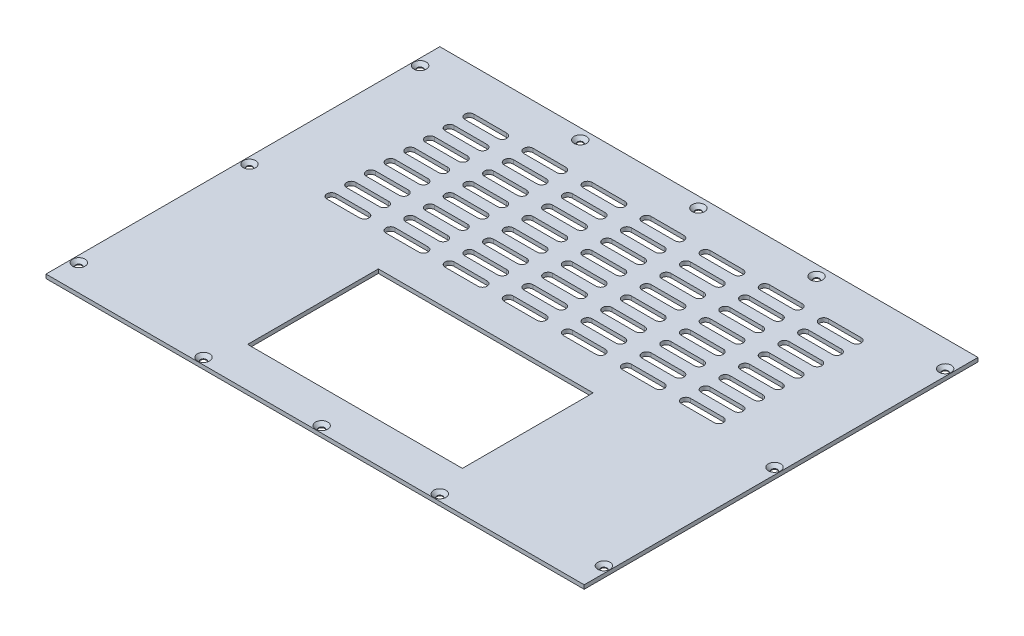
from build123d import *

# Parameters (mm, degrees)
SKETCH_1_W                   = 410
SKETCH_1_H                   = 300
EXTRUDE_1_DEPTH              = 3
HOLE_WIZARD_M4_1_AT_2_COUNT  = 2
HOLE_WIZARD_M4_1_AT_2_PITCH  = 90
HOLE_WIZARD_M4_1_AT_3_COUNT  = 2
HOLE_WIZARD_M4_1_AT_3_PITCH  = 90
HOLE_WIZARD_M4_1_AT_4_COUNT  = 2
HOLE_WIZARD_M4_1_AT_4_PITCH  = 245.283509433
HOLE_WIZARD_M4_1_AT_5_COUNT  = 2
HOLE_WIZARD_M4_1_AT_5_PITCH  = 287
HOLE_WIZARD_M4_1_AT_6_COUNT  = 2
HOLE_WIZARD_M4_1_AT_6_PITCH  = 245.283509433
HOLE_WIZARD_M4_1_AT_7_COUNT  = 2
HOLE_WIZARD_M4_1_AT_7_PITCH  = 200.359676582
HOLE_WIZARD_M4_1_AT_8_COUNT  = 2
HOLE_WIZARD_M4_1_AT_8_PITCH  = 337.615165536
HOLE_WIZARD_M4_1_AT_9_COUNT  = 2
HOLE_WIZARD_M4_1_AT_9_PITCH  = 337.615165536
HOLE_WIZARD_M4_1_AT_10_COUNT = 2
HOLE_WIZARD_M4_1_AT_10_PITCH = 200.359676582
HOLE_WIZARD_M4_1_AT_11_COUNT = 2
HOLE_WIZARD_M4_1_AT_11_PITCH = 300.780650973
HOLE_WIZARD_M4_1_AT_12_COUNT = 2
HOLE_WIZARD_M4_1_AT_12_PITCH = 300.780650973
SKETCH_12_W                  = 163.6
SKETCH_12_H                  = 99.6
CUT_EXTRUDE_1_DEPTH          = 4
CUT_EXTRUDE_3_DEPTH          = 10


with BuildPart() as part:
    # 草圖1 → 填料-伸長1 (new body)
    with BuildSketch(Plane(origin=(0, 0, 0), x_dir=(1, 0, 0), z_dir=(0, 1, 0))):
        Rectangle(SKETCH_1_W, SKETCH_1_H)
    extrude(amount=EXTRUDE_1_DEPTH)

    # 草圖3 → M4 錐坑平頭螺釘的錐孔1 (revolve, cut)
    with BuildSketch(Plane(origin=(0, 3, -142), x_dir=(0, 0, 1), z_dir=(1, 0, 0))):
        Polygon((0, 0), (0, 3), (2.25, 3), (2.25, 2.45), (4.7, 0), align=None)
    hole_wizard_m4_1 = revolve(axis=Axis((0, 9.35, -142), (0, -1, 0)), mode=Mode.SUBTRACT)

    # M4 錐坑平頭螺釘的錐孔1 at 2: M4 錐坑平頭螺釘的錐孔1 ×2
    with Locations(*[(-i * HOLE_WIZARD_M4_1_AT_2_PITCH, 0, 0) for i in range(1, HOLE_WIZARD_M4_1_AT_2_COUNT)]):
        add(hole_wizard_m4_1, mode=Mode.SUBTRACT)

    # M4 錐坑平頭螺釘的錐孔1 at 3: M4 錐坑平頭螺釘的錐孔1 ×2
    with Locations(*[(i * HOLE_WIZARD_M4_1_AT_3_PITCH, 0, 0) for i in range(1, HOLE_WIZARD_M4_1_AT_3_COUNT)]):
        add(hole_wizard_m4_1, mode=Mode.SUBTRACT)

    # M4 錐坑平頭螺釘的錐孔1 at 4: M4 錐坑平頭螺釘的錐孔1 ×2
    with Locations(*[Vector(0.815382985, 0, 0.578921919) * (i * HOLE_WIZARD_M4_1_AT_4_PITCH) for i in range(1, HOLE_WIZARD_M4_1_AT_4_COUNT)]):
        add(hole_wizard_m4_1, mode=Mode.SUBTRACT)

    # M4 錐坑平頭螺釘的錐孔1 at 5: M4 錐坑平頭螺釘的錐孔1 ×2
    with Locations(*[(0, 0, i * HOLE_WIZARD_M4_1_AT_5_PITCH) for i in range(1, HOLE_WIZARD_M4_1_AT_5_COUNT)]):
        add(hole_wizard_m4_1, mode=Mode.SUBTRACT)

    # M4 錐坑平頭螺釘的錐孔1 at 6: M4 錐坑平頭螺釘的錐孔1 ×2
    with Locations(*[Vector(-0.815382985, 0, 0.578921919) * (i * HOLE_WIZARD_M4_1_AT_6_PITCH) for i in range(1, HOLE_WIZARD_M4_1_AT_6_COUNT)]):
        add(hole_wizard_m4_1, mode=Mode.SUBTRACT)

    # M4 錐坑平頭螺釘的錐孔1 at 7: M4 錐坑平頭螺釘的錐孔1 ×2
    with Locations(*[Vector(0.998204845, 0, 0.059892291) * (i * HOLE_WIZARD_M4_1_AT_7_PITCH) for i in range(1, HOLE_WIZARD_M4_1_AT_7_COUNT)]):
        add(hole_wizard_m4_1, mode=Mode.SUBTRACT)

    # M4 錐坑平頭螺釘的錐孔1 at 8: M4 錐坑平頭螺釘的錐孔1 ×2
    with Locations(*[Vector(0.59239045, 0, 0.805651013) * (i * HOLE_WIZARD_M4_1_AT_8_PITCH) for i in range(1, HOLE_WIZARD_M4_1_AT_8_COUNT)]):
        add(hole_wizard_m4_1, mode=Mode.SUBTRACT)

    # M4 錐坑平頭螺釘的錐孔1 at 9: M4 錐坑平頭螺釘的錐孔1 ×2
    with Locations(*[Vector(-0.59239045, 0, 0.805651013) * (i * HOLE_WIZARD_M4_1_AT_9_PITCH) for i in range(1, HOLE_WIZARD_M4_1_AT_9_COUNT)]):
        add(hole_wizard_m4_1, mode=Mode.SUBTRACT)

    # M4 錐坑平頭螺釘的錐孔1 at 10: M4 錐坑平頭螺釘的錐孔1 ×2
    with Locations(*[Vector(-0.998204845, 0, 0.059892291) * (i * HOLE_WIZARD_M4_1_AT_10_PITCH) for i in range(1, HOLE_WIZARD_M4_1_AT_10_COUNT)]):
        add(hole_wizard_m4_1, mode=Mode.SUBTRACT)

    # M4 錐坑平頭螺釘的錐孔1 at 11: M4 錐坑平頭螺釘的錐孔1 ×2
    with Locations(*[Vector(0.299221375, 0, 0.954183719) * (i * HOLE_WIZARD_M4_1_AT_11_PITCH) for i in range(1, HOLE_WIZARD_M4_1_AT_11_COUNT)]):
        add(hole_wizard_m4_1, mode=Mode.SUBTRACT)

    # M4 錐坑平頭螺釘的錐孔1 at 12: M4 錐坑平頭螺釘的錐孔1 ×2
    with Locations(*[Vector(-0.299221375, 0, 0.954183719) * (i * HOLE_WIZARD_M4_1_AT_12_PITCH) for i in range(1, HOLE_WIZARD_M4_1_AT_12_COUNT)]):
        add(hole_wizard_m4_1, mode=Mode.SUBTRACT)

    # 草圖12 → 除料-伸長1 (cut, through all)
    with BuildSketch(Plane.XZ):
        with Locations((0, 69.8)):
            Rectangle(SKETCH_12_W, SKETCH_12_H)
    extrude(amount=-CUT_EXTRUDE_1_DEPTH, mode=Mode.SUBTRACT)

    # 草圖13 → 除料-伸長3 (cut)
    with BuildSketch(Plane(origin=(0, 3, 0), x_dir=(1, 0, 0), z_dir=(0, 1, 0))):
        with BuildLine():
            Line((-147.5, 118.5), (-122.5, 118.5))
            ThreePointArc((-122.5, 118.5), (-119, 115), (-122.5, 111.5))
            Line((-122.5, 111.5), (-147.5, 111.5))
            ThreePointArc((-147.5, 111.5), (-151, 115), (-147.5, 118.5))
        make_face()
        with BuildLine():
            Line((-102.5, 118.5), (-77.5, 118.5))
            ThreePointArc((-77.5, 118.5), (-74, 115), (-77.5, 111.5))
            Line((-77.5, 111.5), (-102.5, 111.5))
            ThreePointArc((-102.5, 111.5), (-106, 115), (-102.5, 118.5))
        make_face()
        with BuildLine():
            Line((-57.5, 118.5), (-32.5, 118.5))
            ThreePointArc((-32.5, 118.5), (-29, 115), (-32.5, 111.5))
            Line((-32.5, 111.5), (-57.5, 111.5))
            ThreePointArc((-57.5, 111.5), (-61, 115), (-57.5, 118.5))
        make_face()
        with BuildLine():
            Line((-12.5, 118.5), (12.5, 118.5))
            ThreePointArc((12.5, 118.5), (16, 115), (12.5, 111.5))
            Line((12.5, 111.5), (-12.5, 111.5))
            ThreePointArc((-12.5, 111.5), (-16, 115), (-12.5, 118.5))
        make_face()
        with BuildLine():
            Line((32.5, 118.5), (57.5, 118.5))
            ThreePointArc((57.5, 118.5), (61, 115), (57.5, 111.5))
            Line((57.5, 111.5), (32.5, 111.5))
            ThreePointArc((32.5, 111.5), (29, 115), (32.5, 118.5))
        make_face()
        with BuildLine():
            Line((77.5, 118.5), (102.5, 118.5))
            ThreePointArc((102.5, 118.5), (106, 115), (102.5, 111.5))
            Line((102.5, 111.5), (77.5, 111.5))
            ThreePointArc((77.5, 111.5), (74, 115), (77.5, 118.5))
        make_face()
        with BuildLine():
            Line((122.5, 118.5), (147.5, 118.5))
            ThreePointArc((147.5, 118.5), (151, 115), (147.5, 111.5))
            Line((147.5, 111.5), (122.5, 111.5))
            ThreePointArc((122.5, 111.5), (119, 115), (122.5, 118.5))
        make_face()
        with BuildLine():
            Line((-102.5, 103.5), (-77.5, 103.5))
            ThreePointArc((-77.5, 103.5), (-74, 100), (-77.5, 96.5))
            Line((-77.5, 96.5), (-102.5, 96.5))
            ThreePointArc((-102.5, 96.5), (-106, 100), (-102.5, 103.5))
        make_face()
        with BuildLine():
            Line((-57.5, 103.5), (-32.5, 103.5))
            ThreePointArc((-32.5, 103.5), (-29, 100), (-32.5, 96.5))
            Line((-32.5, 96.5), (-57.5, 96.5))
            ThreePointArc((-57.5, 96.5), (-61, 100), (-57.5, 103.5))
        make_face()
        with BuildLine():
            Line((-12.5, 103.5), (12.5, 103.5))
            ThreePointArc((12.5, 103.5), (16, 100), (12.5, 96.5))
            Line((12.5, 96.5), (-12.5, 96.5))
            ThreePointArc((-12.5, 96.5), (-16, 100), (-12.5, 103.5))
        make_face()
        with BuildLine():
            Line((32.5, 103.5), (57.5, 103.5))
            ThreePointArc((57.5, 103.5), (61, 100), (57.5, 96.5))
            Line((57.5, 96.5), (32.5, 96.5))
            ThreePointArc((32.5, 96.5), (29, 100), (32.5, 103.5))
        make_face()
        with BuildLine():
            Line((77.5, 103.5), (102.5, 103.5))
            ThreePointArc((102.5, 103.5), (106, 100), (102.5, 96.5))
            Line((102.5, 96.5), (77.5, 96.5))
            ThreePointArc((77.5, 96.5), (74, 100), (77.5, 103.5))
        make_face()
        with BuildLine():
            Line((122.5, 103.5), (147.5, 103.5))
            ThreePointArc((147.5, 103.5), (151, 100), (147.5, 96.5))
            Line((147.5, 96.5), (122.5, 96.5))
            ThreePointArc((122.5, 96.5), (119, 100), (122.5, 103.5))
        make_face()
        with BuildLine():
            Line((-102.5, 88.5), (-77.5, 88.5))
            ThreePointArc((-77.5, 88.5), (-74, 85), (-77.5, 81.5))
            Line((-77.5, 81.5), (-102.5, 81.5))
            ThreePointArc((-102.5, 81.5), (-106, 85), (-102.5, 88.5))
        make_face()
        with BuildLine():
            Line((-57.5, 88.5), (-32.5, 88.5))
            ThreePointArc((-32.5, 88.5), (-29, 85), (-32.5, 81.5))
            Line((-32.5, 81.5), (-57.5, 81.5))
            ThreePointArc((-57.5, 81.5), (-61, 85), (-57.5, 88.5))
        make_face()
        with BuildLine():
            Line((-12.5, 88.5), (12.5, 88.5))
            ThreePointArc((12.5, 88.5), (16, 85), (12.5, 81.5))
            Line((12.5, 81.5), (-12.5, 81.5))
            ThreePointArc((-12.5, 81.5), (-16, 85), (-12.5, 88.5))
        make_face()
        with BuildLine():
            Line((32.5, 88.5), (57.5, 88.5))
            ThreePointArc((57.5, 88.5), (61, 85), (57.5, 81.5))
            Line((57.5, 81.5), (32.5, 81.5))
            ThreePointArc((32.5, 81.5), (29, 85), (32.5, 88.5))
        make_face()
        with BuildLine():
            Line((77.5, 88.5), (102.5, 88.5))
            ThreePointArc((102.5, 88.5), (106, 85), (102.5, 81.5))
            Line((102.5, 81.5), (77.5, 81.5))
            ThreePointArc((77.5, 81.5), (74, 85), (77.5, 88.5))
        make_face()
        with BuildLine():
            Line((122.5, 88.5), (147.5, 88.5))
            ThreePointArc((147.5, 88.5), (151, 85), (147.5, 81.5))
            Line((147.5, 81.5), (122.5, 81.5))
            ThreePointArc((122.5, 81.5), (119, 85), (122.5, 88.5))
        make_face()
        with BuildLine():
            Line((-102.5, 73.5), (-77.5, 73.5))
            ThreePointArc((-77.5, 73.5), (-74, 70), (-77.5, 66.5))
            Line((-77.5, 66.5), (-102.5, 66.5))
            ThreePointArc((-102.5, 66.5), (-106, 70), (-102.5, 73.5))
        make_face()
        with BuildLine():
            Line((-57.5, 73.5), (-32.5, 73.5))
            ThreePointArc((-32.5, 73.5), (-29, 70), (-32.5, 66.5))
            Line((-32.5, 66.5), (-57.5, 66.5))
            ThreePointArc((-57.5, 66.5), (-61, 70), (-57.5, 73.5))
        make_face()
        with BuildLine():
            Line((-12.5, 73.5), (12.5, 73.5))
            ThreePointArc((12.5, 73.5), (16, 70), (12.5, 66.5))
            Line((12.5, 66.5), (-12.5, 66.5))
            ThreePointArc((-12.5, 66.5), (-16, 70), (-12.5, 73.5))
        make_face()
        with BuildLine():
            Line((32.5, 73.5), (57.5, 73.5))
            ThreePointArc((57.5, 73.5), (61, 70), (57.5, 66.5))
            Line((57.5, 66.5), (32.5, 66.5))
            ThreePointArc((32.5, 66.5), (29, 70), (32.5, 73.5))
        make_face()
        with BuildLine():
            Line((77.5, 73.5), (102.5, 73.5))
            ThreePointArc((102.5, 73.5), (106, 70), (102.5, 66.5))
            Line((102.5, 66.5), (77.5, 66.5))
            ThreePointArc((77.5, 66.5), (74, 70), (77.5, 73.5))
        make_face()
        with BuildLine():
            Line((122.5, 73.5), (147.5, 73.5))
            ThreePointArc((147.5, 73.5), (151, 70), (147.5, 66.5))
            Line((147.5, 66.5), (122.5, 66.5))
            ThreePointArc((122.5, 66.5), (119, 70), (122.5, 73.5))
        make_face()
        with BuildLine():
            Line((-102.5, 58.5), (-77.5, 58.5))
            ThreePointArc((-77.5, 58.5), (-74, 55), (-77.5, 51.5))
            Line((-77.5, 51.5), (-102.5, 51.5))
            ThreePointArc((-102.5, 51.5), (-106, 55), (-102.5, 58.5))
        make_face()
        with BuildLine():
            Line((-57.5, 58.5), (-32.5, 58.5))
            ThreePointArc((-32.5, 58.5), (-29, 55), (-32.5, 51.5))
            Line((-32.5, 51.5), (-57.5, 51.5))
            ThreePointArc((-57.5, 51.5), (-61, 55), (-57.5, 58.5))
        make_face()
        with BuildLine():
            Line((-12.5, 58.5), (12.5, 58.5))
            ThreePointArc((12.5, 58.5), (16, 55), (12.5, 51.5))
            Line((12.5, 51.5), (-12.5, 51.5))
            ThreePointArc((-12.5, 51.5), (-16, 55), (-12.5, 58.5))
        make_face()
        with BuildLine():
            Line((32.5, 58.5), (57.5, 58.5))
            ThreePointArc((57.5, 58.5), (61, 55), (57.5, 51.5))
            Line((57.5, 51.5), (32.5, 51.5))
            ThreePointArc((32.5, 51.5), (29, 55), (32.5, 58.5))
        make_face()
        with BuildLine():
            Line((77.5, 58.5), (102.5, 58.5))
            ThreePointArc((102.5, 58.5), (106, 55), (102.5, 51.5))
            Line((102.5, 51.5), (77.5, 51.5))
            ThreePointArc((77.5, 51.5), (74, 55), (77.5, 58.5))
        make_face()
        with BuildLine():
            Line((122.5, 58.5), (147.5, 58.5))
            ThreePointArc((147.5, 58.5), (151, 55), (147.5, 51.5))
            Line((147.5, 51.5), (122.5, 51.5))
            ThreePointArc((122.5, 51.5), (119, 55), (122.5, 58.5))
        make_face()
        with BuildLine():
            Line((-102.5, 43.5), (-77.5, 43.5))
            ThreePointArc((-77.5, 43.5), (-74, 40), (-77.5, 36.5))
            Line((-77.5, 36.5), (-102.5, 36.5))
            ThreePointArc((-102.5, 36.5), (-106, 40), (-102.5, 43.5))
        make_face()
        with BuildLine():
            Line((-57.5, 43.5), (-32.5, 43.5))
            ThreePointArc((-32.5, 43.5), (-29, 40), (-32.5, 36.5))
            Line((-32.5, 36.5), (-57.5, 36.5))
            ThreePointArc((-57.5, 36.5), (-61, 40), (-57.5, 43.5))
        make_face()
        with BuildLine():
            Line((-12.5, 43.5), (12.5, 43.5))
            ThreePointArc((12.5, 43.5), (16, 40), (12.5, 36.5))
            Line((12.5, 36.5), (-12.5, 36.5))
            ThreePointArc((-12.5, 36.5), (-16, 40), (-12.5, 43.5))
        make_face()
        with BuildLine():
            Line((32.5, 43.5), (57.5, 43.5))
            ThreePointArc((57.5, 43.5), (61, 40), (57.5, 36.5))
            Line((57.5, 36.5), (32.5, 36.5))
            ThreePointArc((32.5, 36.5), (29, 40), (32.5, 43.5))
        make_face()
        with BuildLine():
            Line((77.5, 43.5), (102.5, 43.5))
            ThreePointArc((102.5, 43.5), (106, 40), (102.5, 36.5))
            Line((102.5, 36.5), (77.5, 36.5))
            ThreePointArc((77.5, 36.5), (74, 40), (77.5, 43.5))
        make_face()
        with BuildLine():
            Line((122.5, 43.5), (147.5, 43.5))
            ThreePointArc((147.5, 43.5), (151, 40), (147.5, 36.5))
            Line((147.5, 36.5), (122.5, 36.5))
            ThreePointArc((122.5, 36.5), (119, 40), (122.5, 43.5))
        make_face()
        with BuildLine():
            Line((-102.5, 28.5), (-77.5, 28.5))
            ThreePointArc((-77.5, 28.5), (-74, 25), (-77.5, 21.5))
            Line((-77.5, 21.5), (-102.5, 21.5))
            ThreePointArc((-102.5, 21.5), (-106, 25), (-102.5, 28.5))
        make_face()
        with BuildLine():
            Line((-57.5, 28.5), (-32.5, 28.5))
            ThreePointArc((-32.5, 28.5), (-29, 25), (-32.5, 21.5))
            Line((-32.5, 21.5), (-57.5, 21.5))
            ThreePointArc((-57.5, 21.5), (-61, 25), (-57.5, 28.5))
        make_face()
        with BuildLine():
            Line((-12.5, 28.5), (12.5, 28.5))
            ThreePointArc((12.5, 28.5), (16, 25), (12.5, 21.5))
            Line((12.5, 21.5), (-12.5, 21.5))
            ThreePointArc((-12.5, 21.5), (-16, 25), (-12.5, 28.5))
        make_face()
        with BuildLine():
            Line((32.5, 28.5), (57.5, 28.5))
            ThreePointArc((57.5, 28.5), (61, 25), (57.5, 21.5))
            Line((57.5, 21.5), (32.5, 21.5))
            ThreePointArc((32.5, 21.5), (29, 25), (32.5, 28.5))
        make_face()
        with BuildLine():
            Line((77.5, 28.5), (102.5, 28.5))
            ThreePointArc((102.5, 28.5), (106, 25), (102.5, 21.5))
            Line((102.5, 21.5), (77.5, 21.5))
            ThreePointArc((77.5, 21.5), (74, 25), (77.5, 28.5))
        make_face()
        with BuildLine():
            Line((122.5, 28.5), (147.5, 28.5))
            ThreePointArc((147.5, 28.5), (151, 25), (147.5, 21.5))
            Line((147.5, 21.5), (122.5, 21.5))
            ThreePointArc((122.5, 21.5), (119, 25), (122.5, 28.5))
        make_face()
        with BuildLine():
            Line((-102.5, 13.5), (-77.5, 13.5))
            ThreePointArc((-77.5, 13.5), (-74, 10), (-77.5, 6.5))
            Line((-77.5, 6.5), (-102.5, 6.5))
            ThreePointArc((-102.5, 6.5), (-106, 10), (-102.5, 13.5))
        make_face()
        with BuildLine():
            Line((-57.5, 13.5), (-32.5, 13.5))
            ThreePointArc((-32.5, 13.5), (-29, 10), (-32.5, 6.5))
            Line((-32.5, 6.5), (-57.5, 6.5))
            ThreePointArc((-57.5, 6.5), (-61, 10), (-57.5, 13.5))
        make_face()
        with BuildLine():
            Line((-12.5, 13.5), (12.5, 13.5))
            ThreePointArc((12.5, 13.5), (16, 10), (12.5, 6.5))
            Line((12.5, 6.5), (-12.5, 6.5))
            ThreePointArc((-12.5, 6.5), (-16, 10), (-12.5, 13.5))
        make_face()
        with BuildLine():
            Line((32.5, 13.5), (57.5, 13.5))
            ThreePointArc((57.5, 13.5), (61, 10), (57.5, 6.5))
            Line((57.5, 6.5), (32.5, 6.5))
            ThreePointArc((32.5, 6.5), (29, 10), (32.5, 13.5))
        make_face()
        with BuildLine():
            Line((77.5, 13.5), (102.5, 13.5))
            ThreePointArc((102.5, 13.5), (106, 10), (102.5, 6.5))
            Line((102.5, 6.5), (77.5, 6.5))
            ThreePointArc((77.5, 6.5), (74, 10), (77.5, 13.5))
        make_face()
        with BuildLine():
            Line((122.5, 13.5), (147.5, 13.5))
            ThreePointArc((147.5, 13.5), (151, 10), (147.5, 6.5))
            Line((147.5, 6.5), (122.5, 6.5))
            ThreePointArc((122.5, 6.5), (119, 10), (122.5, 13.5))
        make_face()
        with BuildLine():
            Line((-147.5, 103.5), (-122.5, 103.5))
            ThreePointArc((-122.5, 103.5), (-119, 100), (-122.5, 96.5))
            Line((-122.5, 96.5), (-147.5, 96.5))
            ThreePointArc((-147.5, 96.5), (-151, 100), (-147.5, 103.5))
        make_face()
        with BuildLine():
            Line((-147.5, 88.5), (-122.5, 88.5))
            ThreePointArc((-122.5, 88.5), (-119, 85), (-122.5, 81.5))
            Line((-122.5, 81.5), (-147.5, 81.5))
            ThreePointArc((-147.5, 81.5), (-151, 85), (-147.5, 88.5))
        make_face()
        with BuildLine():
            Line((-147.5, 73.5), (-122.5, 73.5))
            ThreePointArc((-122.5, 73.5), (-119, 70), (-122.5, 66.5))
            Line((-122.5, 66.5), (-147.5, 66.5))
            ThreePointArc((-147.5, 66.5), (-151, 70), (-147.5, 73.5))
        make_face()
        with BuildLine():
            Line((-147.5, 58.5), (-122.5, 58.5))
            ThreePointArc((-122.5, 58.5), (-119, 55), (-122.5, 51.5))
            Line((-122.5, 51.5), (-147.5, 51.5))
            ThreePointArc((-147.5, 51.5), (-151, 55), (-147.5, 58.5))
        make_face()
        with BuildLine():
            Line((-147.5, 43.5), (-122.5, 43.5))
            ThreePointArc((-122.5, 43.5), (-119, 40), (-122.5, 36.5))
            Line((-122.5, 36.5), (-147.5, 36.5))
            ThreePointArc((-147.5, 36.5), (-151, 40), (-147.5, 43.5))
        make_face()
        with BuildLine():
            Line((-147.5, 28.5), (-122.5, 28.5))
            ThreePointArc((-122.5, 28.5), (-119, 25), (-122.5, 21.5))
            Line((-122.5, 21.5), (-147.5, 21.5))
            ThreePointArc((-147.5, 21.5), (-151, 25), (-147.5, 28.5))
        make_face()
        with BuildLine():
            Line((-147.5, 13.5), (-122.5, 13.5))
            ThreePointArc((-122.5, 13.5), (-119, 10), (-122.5, 6.5))
            Line((-122.5, 6.5), (-147.5, 6.5))
            ThreePointArc((-147.5, 6.5), (-151, 10), (-147.5, 13.5))
        make_face()
    extrude(amount=-CUT_EXTRUDE_3_DEPTH, mode=Mode.SUBTRACT)


solid = part.part
